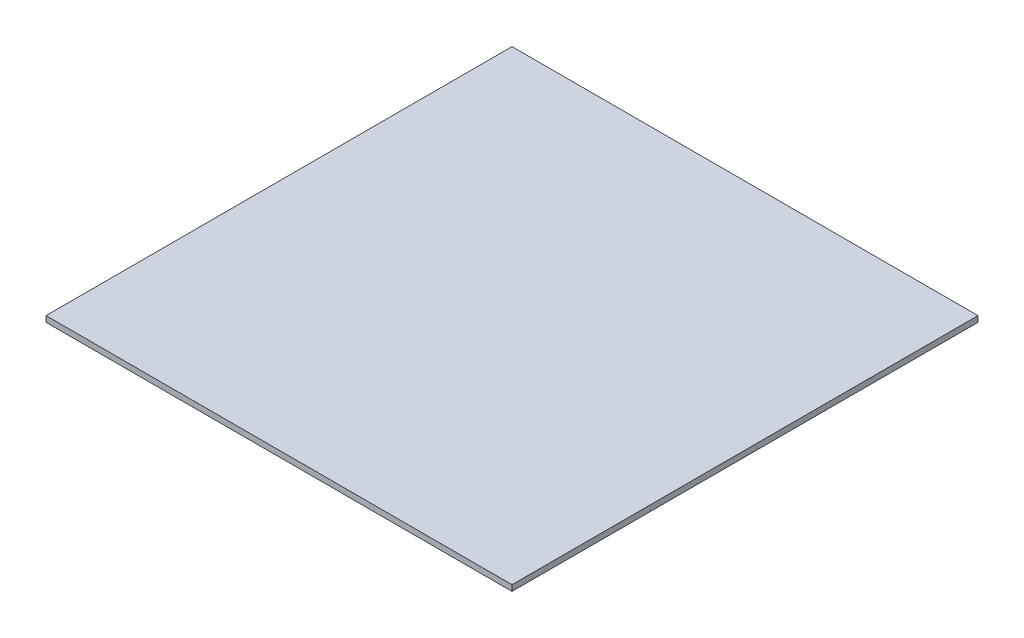
from build123d import *

# Parameters (mm, degrees)
SKETCH1_W           = 800
SKETCH1_H           = 800
BOSS_EXTRUDE1_DEPTH = 10


with BuildPart() as part:
    # Sketch1 → Boss-Extrude1 (new body)
    with BuildSketch(Plane(origin=(0, 0, 0), x_dir=(1, 0, 0), z_dir=(0, 1, 0))):
        with Locations((93.719227428, 48.185352771)):
            Rectangle(SKETCH1_W, SKETCH1_H)
    extrude(amount=BOSS_EXTRUDE1_DEPTH)


solid = part.part
